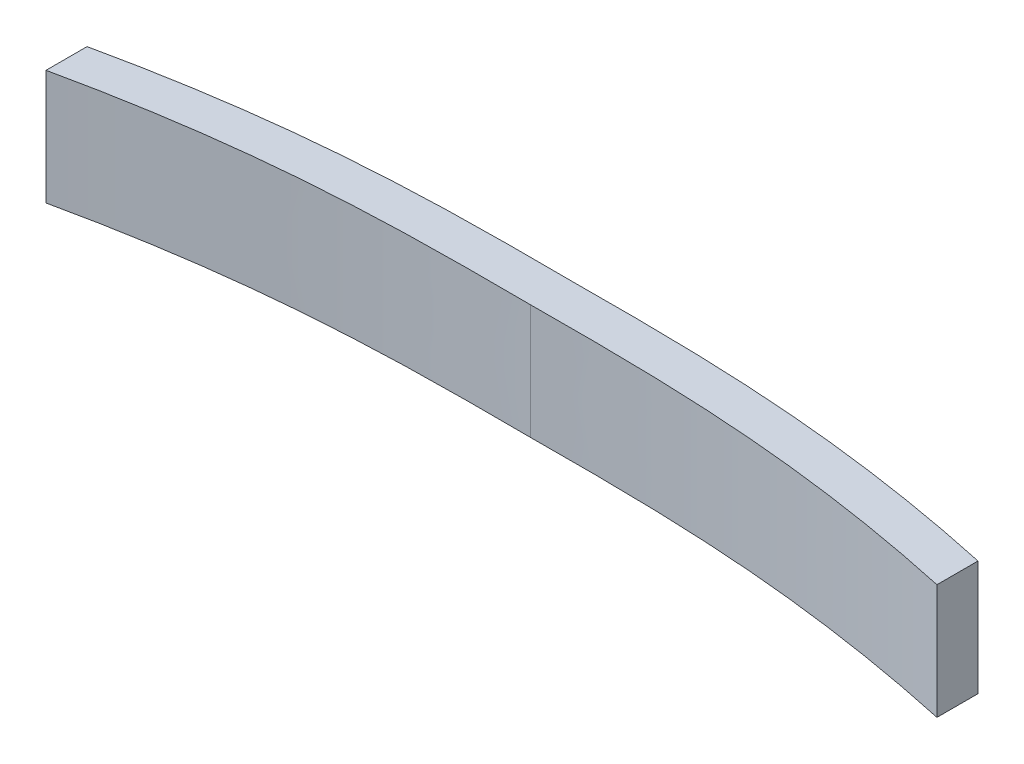
from build123d import *

# Parameters (mm, degrees)
BOSS_EXTRUDE1_DEPTH = 14


with BuildPart() as part:
    # Sketch1 → Boss-Extrude1 (new body)
    with BuildSketch(Plane(origin=(0, 0, 0), x_dir=(1, 0, 0), z_dir=(0, 1, 0))):
        with BuildLine():
            Line((-56.7108806, 8.042770274), (-56.7108806, 3.042770274))
            add(Edge.make_bspline(
                [(-56.7108806, 3.042770274), (-48.323705975, 4.870534091), (-35.02737225, 6.93787877), (-16.87934757, 7.860332352), (-7.605819721, 7.844934175), (-2.44151388, 7.817702683)],
                knots=[0, 0, 0, 0, 0.47203113, 0.735860593, 1, 1, 1, 1], degree=3))
            add(Edge.make_bspline(
                [(-2.44151388, 7.817702683), (2.722791962, 7.844934175), (11.99631981, 7.860332352), (30.144344491, 6.93787877), (43.440678216, 4.870534091), (51.827852841, 3.042770274)],
                knots=[0.442922252, 0.442922252, 0.442922252, 0.442922252, 0.707061659, 0.970891122, 1.442922252, 1.442922252, 1.442922252, 1.442922252], degree=3))
            Line((51.827852841, 3.042770274), (51.827852841, 8.042770274))
            add(Edge.make_bspline(
                [(51.827852841, 8.042770274), (43.440678216, 9.870534091), (30.144344491, 11.93787877), (11.99631981, 12.860332352), (2.722791962, 12.844934175), (-2.44151388, 12.817702683)],
                knots=[0, 0, 0, 0, 0.47203113, 0.735860593, 1, 1, 1, 1], degree=3))
            add(Edge.make_bspline(
                [(-56.7108806, 8.042770274), (-48.323705975, 9.870534091), (-35.02737225, 11.93787877), (-16.87934757, 12.860332352), (-7.605819721, 12.844934175), (-2.44151388, 12.817702683)],
                knots=[0, 0, 0, 0, 0.47203113, 0.735860593, 1, 1, 1, 1], degree=3))
        make_face()
    extrude(amount=BOSS_EXTRUDE1_DEPTH)


solid = part.part
